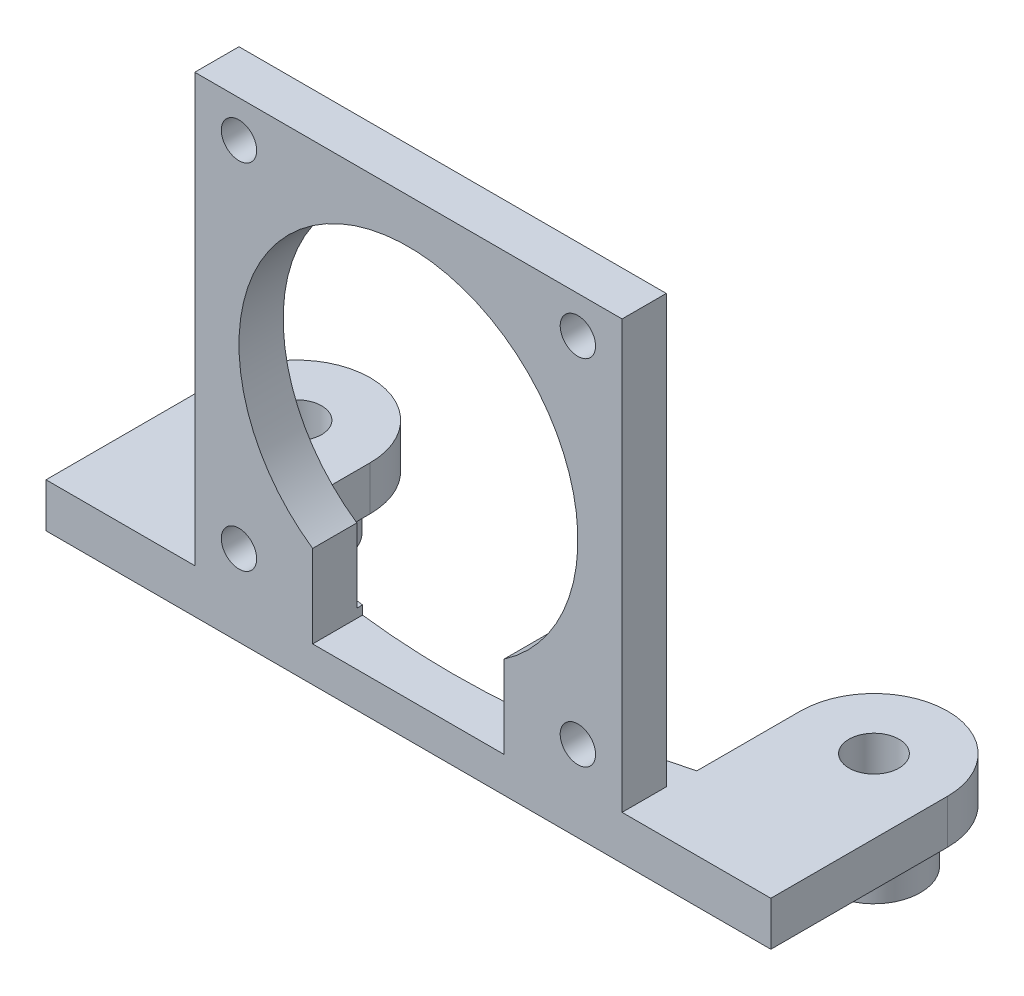
from build123d import *

# Parameters (mm, degrees)
SKETCH1_R           = 1.7
BOSS_EXTRUDE2_DEPTH = 3
SKETCH1_7_W         = 29
SKETCH1_7_H         = 3
BOSS_EXTRUDE4_DEPTH = 29
CUT_EXTRUDE1_REACH  = 43.653
SKETCH2_R           = 1.2
BOSS_EXTRUDE3_START = -3
SKETCH1_5_R         = 3.15
SKETCH1_5_R_2       = 1.7
BOSS_EXTRUDE3_DEPTH = 3.6


with BuildPart() as part:
    # Sketch1 → Boss-Extrude2 (new body)
    with BuildSketch(Plane(origin=(0, 0, 0), x_dir=(1, 0, 0), z_dir=(0, 1, 0))):
        with BuildLine():
            ThreePointArc((24.595917942, -46), (19.595917942, -41), (14.595917942, -46))
            Line((14.595917942, -46), (14.595917942, -53.027909439))
            ThreePointArc((14.595917942, -53.027909439), (0, -55), (-14.595917942, -53.027909439))
            Line((-14.595917942, -53.027909439), (-14.595917942, -46))
            ThreePointArc((-14.595917942, -46), (-19.595917942, -41), (-24.595917942, -46))
            Line((-24.595917942, -46), (-24.595917942, -58))
            Line((-24.595917942, -58), (24.595917942, -58))
            Line((24.595917942, -58), (24.595917942, -46))
        make_face()
        with Locations(Location((-19.595917942, -46, 0), (0, 0, 270))):
            Circle(SKETCH1_R, mode=Mode.SUBTRACT)
        with Locations(Location((19.595917942, -46, 0), (0, 0, 270))):
            Circle(SKETCH1_R, mode=Mode.SUBTRACT)
    extrude(amount=-BOSS_EXTRUDE2_DEPTH)

    # Sketch1_7 → Boss-Extrude4 (add)
    with BuildSketch(Plane(origin=(0, 0, 0), x_dir=(1, 0, 0), z_dir=(0, 1, 0))):
        with Locations((0, -56.5)):
            Rectangle(SKETCH1_7_W, SKETCH1_7_H)
    extrude(amount=BOSS_EXTRUDE4_DEPTH)

    # Sketch2 → Cut-Extrude1 (cut, up to next)
    with BuildSketch(Plane.XY.offset(58), mode=Mode.PRIVATE) as cut_extrude1_sk1:
        with BuildLine():
            Line((-6.5, 5.013167019), (-6.5, -0.6))
            Line((-6.5, -0.6), (6.5, -0.6))
            Line((6.5, -0.6), (6.5, 5.013167019))
            ThreePointArc((6.5, 5.013167019), (0, 26), (-6.5, 5.013167019))
        make_face()
    cut_extrude1_tool1 = extrude(cut_extrude1_sk1.sketch, amount=-CUT_EXTRUDE1_REACH, mode=Mode.PRIVATE) & part.part
    # Sketch2 → Cut-Extrude1 (cut, up to next)
    with BuildSketch(Plane.XY.offset(58), mode=Mode.PRIVATE) as cut_extrude1_sk2:
        with Locations((-11.5, 2.5)):
            Circle(SKETCH2_R)
    cut_extrude1_tool2 = extrude(cut_extrude1_sk2.sketch, amount=-CUT_EXTRUDE1_REACH, mode=Mode.PRIVATE) & part.part
    # Sketch2 → Cut-Extrude1 (cut, up to next)
    with BuildSketch(Plane.XY.offset(58), mode=Mode.PRIVATE) as cut_extrude1_sk3:
        with Locations((-11.5, 26.5)):
            Circle(SKETCH2_R)
    cut_extrude1_tool3 = extrude(cut_extrude1_sk3.sketch, amount=-CUT_EXTRUDE1_REACH, mode=Mode.PRIVATE) & part.part
    # Sketch2 → Cut-Extrude1 (cut, up to next)
    with BuildSketch(Plane.XY.offset(58), mode=Mode.PRIVATE) as cut_extrude1_sk4:
        with Locations((11.5, 2.5)):
            Circle(SKETCH2_R)
    cut_extrude1_tool4 = extrude(cut_extrude1_sk4.sketch, amount=-CUT_EXTRUDE1_REACH, mode=Mode.PRIVATE) & part.part
    # Sketch2 → Cut-Extrude1 (cut, up to next)
    with BuildSketch(Plane.XY.offset(58), mode=Mode.PRIVATE) as cut_extrude1_sk5:
        with Locations((11.5, 26.5)):
            Circle(SKETCH2_R)
    cut_extrude1_tool5 = extrude(cut_extrude1_sk5.sketch, amount=-CUT_EXTRUDE1_REACH, mode=Mode.PRIVATE) & part.part
    add(cut_extrude1_tool1.solids().sort_by_distance((0, 12.98305, 58))[0], mode=Mode.SUBTRACT)
    add(cut_extrude1_tool2.solids().sort_by_distance((-11.5, 2.5, 58))[0], mode=Mode.SUBTRACT)
    add(cut_extrude1_tool3.solids().sort_by_distance((-11.5, 26.5, 58))[0], mode=Mode.SUBTRACT)
    add(cut_extrude1_tool4.solids().sort_by_distance((11.5, 2.5, 58))[0], mode=Mode.SUBTRACT)
    add(cut_extrude1_tool5.solids().sort_by_distance((11.5, 26.5, 58))[0], mode=Mode.SUBTRACT)

    # Sketch1_5 → Boss-Extrude3 (add)
    with BuildSketch(Plane(origin=(0, 0, 0), x_dir=(1, 0, 0), z_dir=(0, 1, 0)).offset(BOSS_EXTRUDE3_START)):
        with Locations(Location((-19.595917942, -46, 0), (0, 0, 270))):
            Circle(SKETCH1_5_R)
        with Locations(Location((-19.595917942, -46, 0), (0, 0, 270))):
            Circle(SKETCH1_5_R_2, mode=Mode.SUBTRACT)
        with Locations(Location((19.595917942, -46, 0), (0, 0, 270))):
            Circle(SKETCH1_5_R)
        with Locations(Location((19.595917942, -46, 0), (0, 0, 270))):
            Circle(SKETCH1_5_R_2, mode=Mode.SUBTRACT)
    extrude(amount=-BOSS_EXTRUDE3_DEPTH)


solid = part.part
